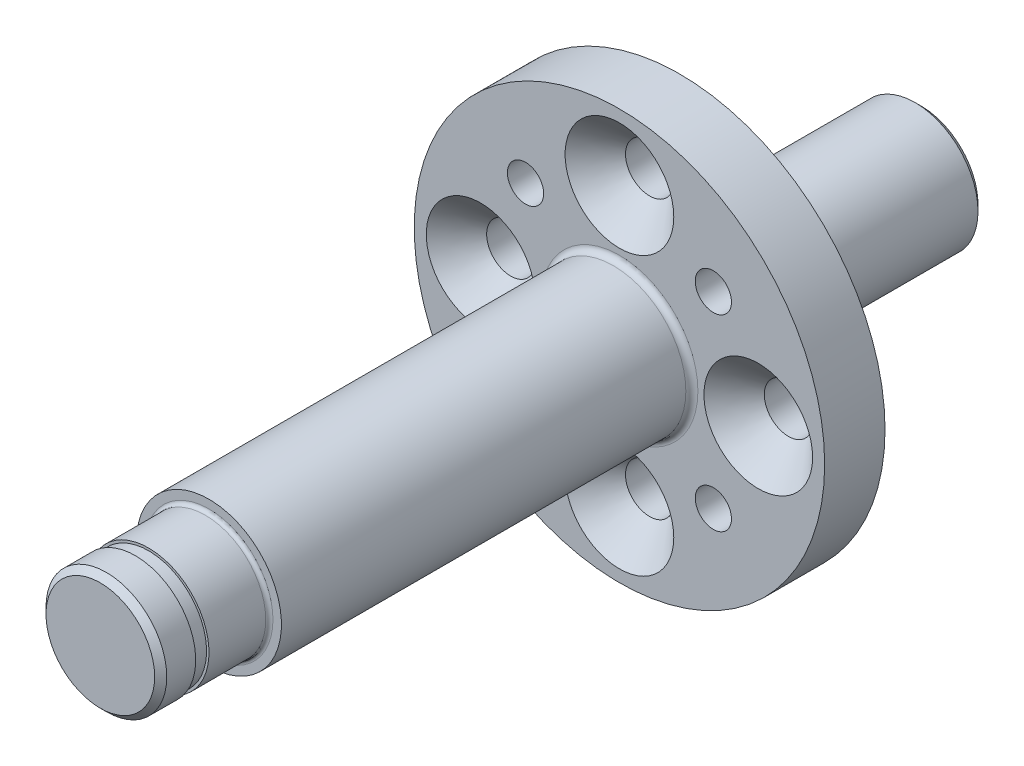
from build123d import *

# Parameters (mm, degrees)
SKETCH1_R                                            = 17
BOSS_EXTRUDE1_DEPTH                                  = 5
SKETCH3_R                                            = 5.2
BOSS_EXTRUDE3_DEPTH                                  = 20
CSK_FOR_M4_HEX_SOCKET_COUNTERSUNK_CAP_SC_D           = 4
CSK_FOR_M4_HEX_SOCKET_COUNTERSUNK_CAP_SC_CSINK_D     = 9
CSK_FOR_M4_HEX_SOCKET_COUNTERSUNK_CAP_SC_CSINK_ANGLE = 90
M4_TAPPED_HOLE1_D                                    = 3
CHAMFER1_SIZE                                        = 0.5
FILLET1_R                                            = 0.3
FILLET2_R                                            = 0.5


with BuildPart() as part:
    # Sketch1 → Boss-Extrude1 (new body)
    with BuildSketch(Plane.XY):
        Circle(SKETCH1_R)
    extrude(amount=BOSS_EXTRUDE1_DEPTH)

    # Sketch3 → Boss-Extrude3 (add)
    with BuildSketch(Plane(origin=(0, 0, 0), x_dir=(-1, 0, 0), z_dir=(0, 0, -1))):
        Circle(SKETCH3_R)
    extrude(amount=BOSS_EXTRUDE3_DEPTH)

    # CSK for M4 Hex Socket Countersunk Cap Screw1 (through all)
    with Locations(Plane.XY.offset(5)):
        with Locations((0, 11.5), (11.5, 0), (0, -11.5), (-11.5, 0)):
            CounterSinkHole(CSK_FOR_M4_HEX_SOCKET_COUNTERSUNK_CAP_SC_D / 2, CSK_FOR_M4_HEX_SOCKET_COUNTERSUNK_CAP_SC_CSINK_D / 2, counter_sink_angle=CSK_FOR_M4_HEX_SOCKET_COUNTERSUNK_CAP_SC_CSINK_ANGLE)

    # M4 Tapped Hole1 (through all)
    with Locations(Plane.XY.offset(5)):
        with Locations((7.778174593, 7.778174593), (-7.778174593, -7.778174593), (-7.778174593, 7.778174593), (7.778174593, -7.778174593)):
            Hole(M4_TAPPED_HOLE1_D / 2)

    # Sketch9 → Revolve1 (revolve)
    with BuildSketch(Plane(origin=(0, 0, 0), x_dir=(0, 0, -1), z_dir=(1, 0, 0))):
        Polygon((-5, 6), (-39, 6), (-39, 5), (-44, 5), (-44, 4.8), (-45.1, 4.8), (-45.1, 5), (-48, 5), (-48, 0), (-5, 0), align=None)
    revolve(axis=Axis((0, 0, -20), (0, 0, 1)))

    # Chamfer1
    chamfer1_edges = [part.edges().sort_by_distance(p)[0] for p in [
        (0, -5, 48),
        (5.2, 0, -20),
    ]]
    chamfer(chamfer1_edges, length=CHAMFER1_SIZE)

    # Fillet1
    fillet1_edges = [part.edges().sort_by_distance(p)[0] for p in [
        (0, -5, 39),
    ]]
    fillet(fillet1_edges, radius=FILLET1_R)

    # Fillet2
    fillet2_edges = [part.edges().sort_by_distance(p)[0] for p in [
        (5.2, 0, 0),
        (0, -6, 5),
    ]]
    fillet(fillet2_edges, radius=FILLET2_R)


solid = part.part
